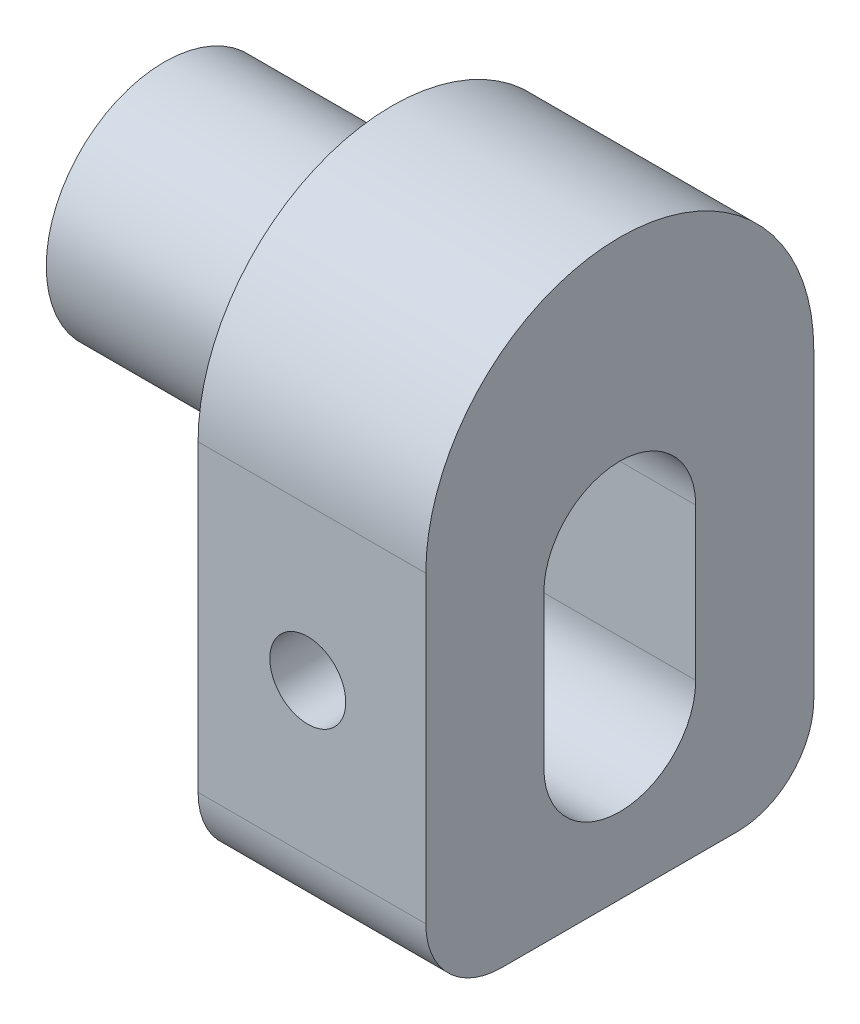
from build123d import *

# Parameters (mm, degrees)
SKETCH1_R           = 3.95
BOSS_EXTRUDE1_DEPTH = 7.62
BOSS_EXTRUDE2_DEPTH = 7.62
BOSS_EXTRUDE3_DEPTH = 7.62
CUT_EXTRUDE1_DEPTH  = 7.62
SKETCH6_R           = 1.27
CUT_EXTRUDE2_DEPTH  = 4.9500048
SKETCH7_R           = 4.445
BOSS_EXTRUDE4_DEPTH = 1.27
FILLET1_R           = 2.54


with BuildPart() as part:
    # Sketch1 → Boss-Extrude1 (new body)
    with BuildSketch(Plane(origin=(0, 0, 0), x_dir=(0, 0, -1), z_dir=(1, 0, 0))):
        Circle(SKETCH1_R)
    extrude(amount=BOSS_EXTRUDE1_DEPTH)

    # Sketch2 → Boss-Extrude2 (add)
    with BuildSketch(Plane(origin=(7.62, 0, 0), x_dir=(0, 0, -1), z_dir=(1, 0, 0))):
        with BuildLine():
            Line((-3.95, 0), (-3.95, -10.16))
            Line((-3.95, -10.16), (3.95, -10.16))
            Line((3.95, -10.16), (3.95, 0))
            ThreePointArc((3.95, 0), (0, 3.95), (-3.95, 0))
        make_face()
    extrude(amount=BOSS_EXTRUDE2_DEPTH)

    # Sketch4 → Boss-Extrude3 (add)
    with BuildSketch(Plane(origin=(15.24, 0, 0), x_dir=(0, 0, -1), z_dir=(1, 0, 0))):
        with BuildLine():
            Line((-6.49, 0), (-6.49, -12.7))
            Line((-6.49, -12.7), (6.49, -12.7))
            Line((6.49, -12.7), (6.49, 0))
            ThreePointArc((6.49, 0), (0, 6.49), (-6.49, 0))
        make_face()
        with BuildLine():
            Line((-3.95, 0), (-3.95, -10.16))
            Line((-3.95, -10.16), (3.95, -10.16))
            Line((3.95, -10.16), (3.95, 0))
            ThreePointArc((3.95, 0), (0, 3.95), (-3.95, 0))
        make_face(mode=Mode.SUBTRACT)
    extrude(amount=-BOSS_EXTRUDE3_DEPTH)

    # Sketch5 → Cut-Extrude1 (cut)
    with BuildSketch(Plane(origin=(15.24, 0, 0), x_dir=(0, 0, -1), z_dir=(1, 0, 0))):
        with BuildLine():
            Line((-2.5399952, -2.54), (-2.5399952, -7.62))
            ThreePointArc((-2.5399952, -7.62), (4.8e-06, -10.16), (2.5400048, -7.62))
            Line((2.5400048, -7.62), (2.5400048, -2.54))
            ThreePointArc((2.5400048, -2.54), (4.8e-06, 0), (-2.5399952, -2.54))
        make_face()
    extrude(amount=-CUT_EXTRUDE1_DEPTH, mode=Mode.SUBTRACT)

    # Sketch6 → Cut-Extrude2 (cut, through all)
    with BuildSketch(Plane(origin=(0, 0, 2.5399952), x_dir=(-1, 0, 0), z_dir=(0, 0, -1))):
        with Locations((-11.290974186, -5.08)):
            Circle(SKETCH6_R)
    extrude(amount=-CUT_EXTRUDE2_DEPTH, mode=Mode.SUBTRACT)

    # Sketch7 → Boss-Extrude4 (add)
    with BuildSketch(Plane.ZY.offset(-7.62)):
        Circle(SKETCH7_R)
    extrude(amount=BOSS_EXTRUDE4_DEPTH)

    # Fillet1
    fillet1_edges = [part.edges().sort_by_distance(p)[0] for p in [
        (11.43, -12.7, -6.49),
        (11.43, -12.7, 6.49),
    ]]
    fillet(fillet1_edges, radius=FILLET1_R)


solid = part.part
